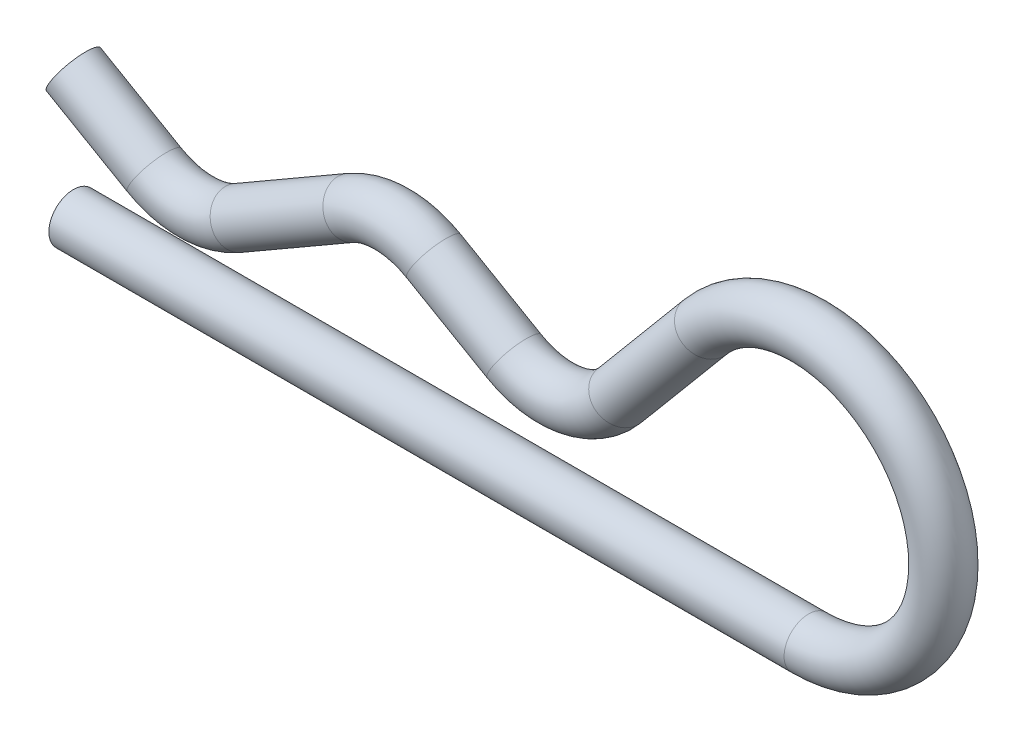
from build123d import *

# Parameters (mm, degrees)
ESQUISSE2_R = 0.5


with BuildPart() as part:
    # Balayage1: sweep along a path in Esquisse1
    with BuildLine(Plane.XY) as balayage1_path:
        Line((0, 0), (15, 0))
        ThreePointArc((15, 0), (17.492346414, 3.91220022), (12.893377781, 4.517665927))
        Line((12.893377781, 4.517665927), (11.143330468, 2.432040753))
        ThreePointArc((11.143330468, 2.432040753), (10.136256816, 1.85060651), (8.991054914, 2.052536503))
        Line((8.991054914, 2.052536503), (7.35, 3))
        ThreePointArc((7.35, 3), (6.5, 3.227756814), (5.65, 3))
        Line((5.65, 3), (3.35, 1.672094381))
        ThreePointArc((3.35, 1.672094381), (2.5, 1.444337567), (1.65, 1.672094381))
        Line((1.65, 1.672094381), (0, 2.624722325))
    # Esquisse2 → Balayage1 (sweep)
    with BuildSketch(Plane(origin=(0, 0, 0), x_dir=(0, 0, -1), z_dir=(1, 0, 0))):
        Circle(ESQUISSE2_R)
    sweep(path=balayage1_path.line)


solid = part.part
